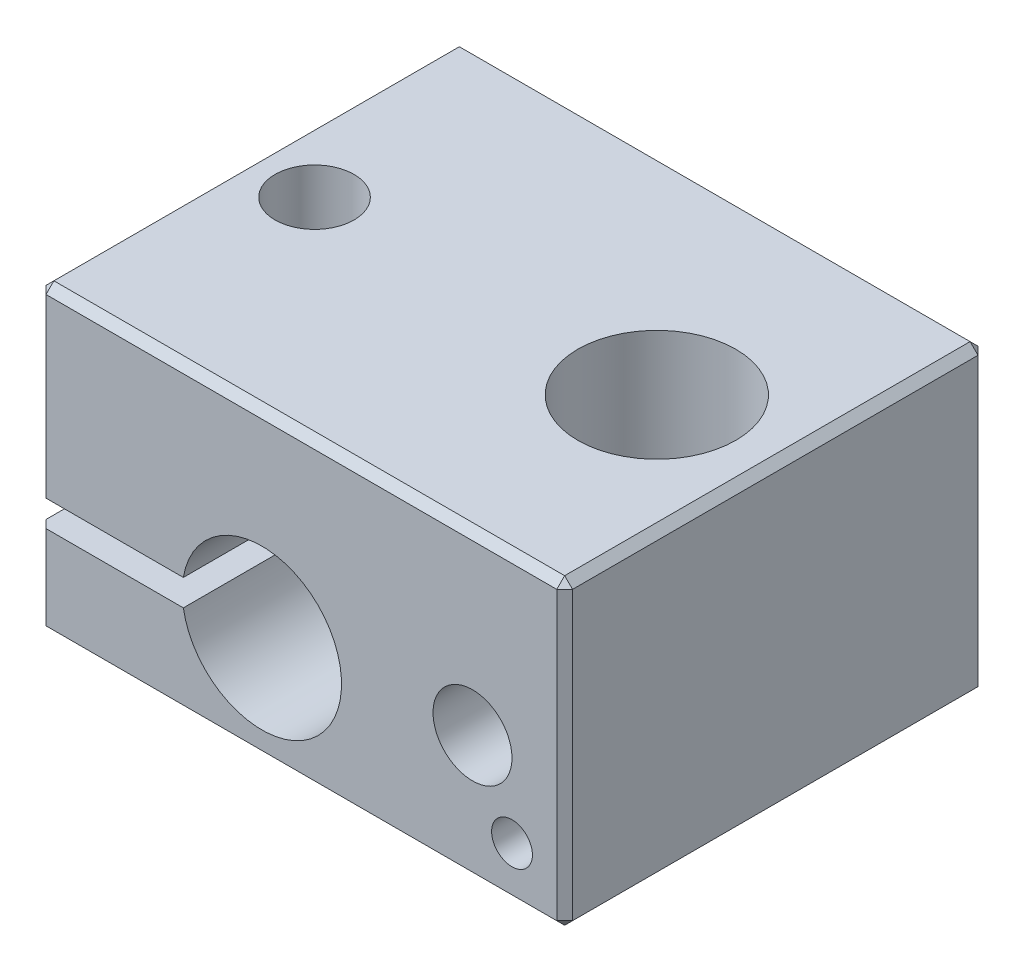
from build123d import *

# Parameters (mm, degrees)
SKETCH1_W           = 20
SKETCH1_H           = 16
SKETCH1_R           = 3
SKETCH1_R_2         = 1.5
BOSS_EXTRUDE1_DEPTH = 11.5
CUT_EXTRUDE1_DEPTH  = 17
SKETCH3_R           = 1.5
SKETCH3_R_2         = 0.775
CUT_EXTRUDE2_DEPTH  = 4
CHAMFER1_SIZE       = 0.3


with BuildPart() as part:
    # Sketch1 → Boss-Extrude1 (new body)
    with BuildSketch(Plane(origin=(0, 0, 0), x_dir=(1, 0, 0), z_dir=(0, 1, 0))):
        with Locations((10, 8)):
            Rectangle(SKETCH1_W, SKETCH1_H)
        with Locations((15.5, 8)):
            Circle(SKETCH1_R, mode=Mode.SUBTRACT)
        with Locations((2.5, 8)):
            Circle(SKETCH1_R_2, mode=Mode.SUBTRACT)
    extrude(amount=BOSS_EXTRUDE1_DEPTH)

    # Sketch2 → Cut-Extrude1 (cut, through all)
    with BuildSketch(Plane.XY):
        with BuildLine():
            Line((5.516608474, 4.5), (11.483391526, 4.5))
            ThreePointArc((11.483391526, 4.5), (8.5, 7.025), (5.516608474, 4.5))
        make_face()
        with BuildLine():
            Line((5.516608474, 3.5), (11.483391526, 3.5))
            ThreePointArc((11.483391526, 3.5), (11.514579935, 3.749135861), (11.525, 4))
            ThreePointArc((11.525, 4), (11.514579935, 4.250864139), (11.483391526, 4.5))
            Line((11.483391526, 4.5), (5.516608474, 4.5))
            ThreePointArc((5.516608474, 4.5), (5.475, 4), (5.516608474, 3.5))
        make_face()
        with BuildLine():
            ThreePointArc((5.516608474, 3.5), (8.5, 0.975), (11.483391526, 3.5))
            Line((11.483391526, 3.5), (5.516608474, 3.5))
        make_face()
        with BuildLine():
            Line((0, 3.5), (5.516608474, 3.5))
            ThreePointArc((5.516608474, 3.5), (5.475, 4), (5.516608474, 4.5))
            Line((5.516608474, 4.5), (0, 4.5))
            Line((0, 4.5), (0, 3.5))
        make_face()
    extrude(amount=-CUT_EXTRUDE1_DEPTH, mode=Mode.SUBTRACT)

    # Sketch3 → Cut-Extrude2 (cut)
    with BuildSketch(Plane.XY):
        with Locations((16.5, 4.8)):
            Circle(SKETCH3_R)
        with Locations((18, 2)):
            Circle(SKETCH3_R_2)
    extrude(amount=-CUT_EXTRUDE2_DEPTH, mode=Mode.SUBTRACT)

    # Chamfer1
    chamfer1_edges = [part.edges().sort_by_distance(p)[0] for p in [
        (20, 11.5, -8),
        (10, 11.5, -16),
        (0, 1.75, -16),
        (0, 1.75, 0),
        (0, 11.5, -8),
        (10, 0, -16),
        (20, 0, -8),
        (10, 0, 0),
        (0, 0, -8),
        (10, 11.5, 0),
        (0, 8, -16),
        (20, 5.75, -16),
        (20, 5.75, 0),
        (0, 8, 0),
    ]]
    chamfer(chamfer1_edges, length=CHAMFER1_SIZE)


solid = part.part
